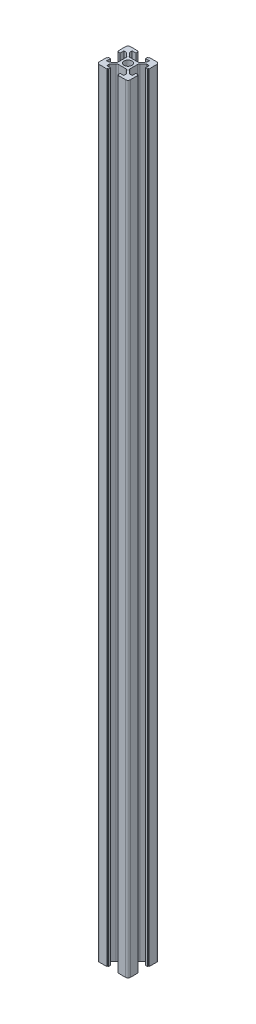
from build123d import *

# Parameters (mm, degrees)
SKETCH1_R           = 2.5
BOSS_EXTRUDE1_DEPTH = 500
SKETCH2_R           = 3
CUT_EXTRUDE1_DEPTH  = 7.6


with BuildPart() as part:
    # Sketch1 → Boss-Extrude1 (new body)
    with BuildSketch(Plane(origin=(0, 0, 0), x_dir=(1, 0, 0), z_dir=(0, 1, 0))):
        with BuildLine():
            ThreePointArc((-10, -8.5), (-9.560660172, -9.560660172), (-8.5, -10))
            Line((-8.5, -10), (-3.6, -10))
            Line((-3.6, -10), (-3.6, -9.5))
            Line((-3.6, -9.5), (-3.1, -9.5))
            Line((-3.1, -9.5), (-3.1, -8.2))
            Line((-3.1, -8.2), (-5.5, -8.2))
            Line((-5.5, -8.2), (-5.5, -6.6))
            Line((-5.5, -6.6), (-3.54898252, -4.32381294))
            ThreePointArc((-3.54898252, -4.32381294), (-3.036882831, -3.937230652), (-2.410097616, -3.8))
            Line((-2.410097616, -3.8), (2.410097616, -3.8))
            ThreePointArc((2.410097616, -3.8), (3.036882831, -3.937230652), (3.54898252, -4.32381294))
            Line((3.54898252, -4.32381294), (5.5, -6.6))
            Line((5.5, -6.6), (5.5, -8.2))
            Line((5.5, -8.2), (3.1, -8.2))
            Line((3.1, -8.2), (3.1, -9.5))
            Line((3.1, -9.5), (3.6, -9.5))
            Line((3.6, -9.5), (3.6, -10))
            Line((3.6, -10), (8.5, -10))
            ThreePointArc((8.5, -10), (9.560660172, -9.560660172), (10, -8.5))
            Line((10, -8.5), (10, -3.6))
            Line((10, -3.6), (9.5, -3.6))
            Line((9.5, -3.6), (9.5, -3.1))
            Line((9.5, -3.1), (8.2, -3.1))
            Line((8.2, -3.1), (8.2, -5.5))
            Line((8.2, -5.5), (6.6, -5.5))
            Line((6.6, -5.5), (4.32381294, -3.54898252))
            ThreePointArc((4.32381294, -3.54898252), (3.937230652, -3.036882831), (3.8, -2.410097616))
            Line((3.8, -2.410097616), (3.8, 2.410097616))
            ThreePointArc((3.8, 2.410097616), (3.937230652, 3.036882831), (4.32381294, 3.54898252))
            Line((4.32381294, 3.54898252), (6.6, 5.5))
            Line((6.6, 5.5), (8.2, 5.5))
            Line((8.2, 5.5), (8.2, 3.1))
            Line((8.2, 3.1), (9.5, 3.1))
            Line((9.5, 3.1), (9.5, 3.6))
            Line((9.5, 3.6), (10, 3.6))
            Line((10, 3.6), (10, 8.5))
            ThreePointArc((10, 8.5), (9.560660172, 9.560660172), (8.5, 10))
            Line((8.5, 10), (3.6, 10))
            Line((3.6, 10), (3.6, 9.5))
            Line((3.6, 9.5), (3.1, 9.5))
            Line((3.1, 9.5), (3.1, 8.2))
            Line((3.1, 8.2), (5.5, 8.2))
            Line((5.5, 8.2), (5.5, 6.6))
            Line((5.5, 6.6), (3.54898252, 4.32381294))
            ThreePointArc((3.54898252, 4.32381294), (3.036882831, 3.937230652), (2.410097616, 3.8))
            Line((2.410097616, 3.8), (-2.410097616, 3.8))
            ThreePointArc((-2.410097616, 3.8), (-3.036882831, 3.937230652), (-3.54898252, 4.32381294))
            Line((-3.54898252, 4.32381294), (-5.5, 6.6))
            Line((-5.5, 6.6), (-5.5, 8.2))
            Line((-5.5, 8.2), (-3.1, 8.2))
            Line((-3.1, 8.2), (-3.1, 9.5))
            Line((-3.1, 9.5), (-3.6, 9.5))
            Line((-3.6, 9.5), (-3.6, 10))
            Line((-3.6, 10), (-8.5, 10))
            ThreePointArc((-8.5, 10), (-9.560660172, 9.560660172), (-10, 8.5))
            Line((-10, 8.5), (-10, 3.6))
            Line((-10, 3.6), (-9.5, 3.6))
            Line((-9.5, 3.6), (-9.5, 3.1))
            Line((-9.5, 3.1), (-8.2, 3.1))
            Line((-8.2, 3.1), (-8.2, 5.5))
            Line((-8.2, 5.5), (-6.6, 5.5))
            Line((-6.6, 5.5), (-4.32381294, 3.54898252))
            ThreePointArc((-4.32381294, 3.54898252), (-3.937230652, 3.036882831), (-3.8, 2.410097616))
            Line((-3.8, 2.410097616), (-3.8, -2.410097616))
            ThreePointArc((-3.8, -2.410097616), (-3.937230652, -3.036882831), (-4.32381294, -3.54898252))
            Line((-4.32381294, -3.54898252), (-6.6, -5.5))
            Line((-6.6, -5.5), (-8.2, -5.5))
            Line((-8.2, -5.5), (-8.2, -3.1))
            Line((-8.2, -3.1), (-9.5, -3.1))
            Line((-9.5, -3.1), (-9.5, -3.6))
            Line((-9.5, -3.6), (-10, -3.6))
            Line((-10, -3.6), (-10, -8.5))
        make_face()
        Circle(SKETCH1_R, mode=Mode.SUBTRACT)
    extrude(amount=BOSS_EXTRUDE1_DEPTH)

    # Sketch2 → Cut-Extrude1 (cut)
    with BuildSketch(Plane(origin=(0, 0, -3.8), x_dir=(-1, 0, 0), z_dir=(0, 0, -1))):
        with Locations((0, 50)):
            Circle(SKETCH2_R)
        with Locations((0, 130)):
            Circle(SKETCH2_R)
        with Locations((0, 210)):
            Circle(SKETCH2_R)
        with Locations((0, 290)):
            Circle(SKETCH2_R)
        with Locations((0, 370)):
            Circle(SKETCH2_R)
        with Locations((0, 450)):
            Circle(SKETCH2_R)
    extrude(amount=-CUT_EXTRUDE1_DEPTH, mode=Mode.SUBTRACT)


solid = part.part
